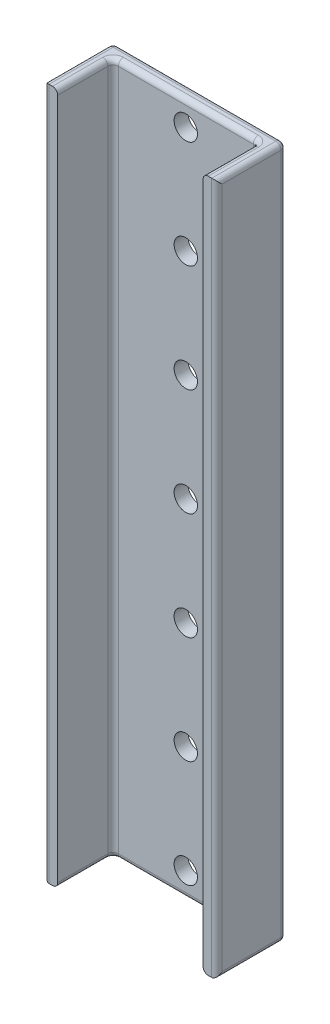
from build123d import *

# Parameters (mm, degrees)
EXTRUIR_L_MINA1_DEPTH         = 400
REDONDEO1_R                   = 3
REDONDEO2_R                   = 3
TALADRO_DE_MARGEN_PARA_M121_D = 13.5


with BuildPart() as part:
    # Croquis1 → Extruir-Lámina1 (new body)
    with BuildSketch(Plane(origin=(0, 0, 0), x_dir=(1, 0, 0), z_dir=(0, 1, 0))):
        with BuildLine():
            Line((50, 0), (50, 37))
            ThreePointArc((50, 37), (49.121320344, 39.121320344), (47, 40))
            Line((47, 40), (-47, 40))
            ThreePointArc((-47, 40), (-49.121320344, 39.121320344), (-50, 37))
            Line((-50, 37), (-50, 0))
            Line((-50, 0), (-42, 0))
            Line((-42, 0), (-42, 32))
            Line((-42, 32), (42, 32))
            Line((42, 32), (42, 0))
            Line((42, 0), (50, 0))
        make_face()
    extrude(amount=EXTRUIR_L_MINA1_DEPTH)

    # Redondeo1
    redondeo1_edges = [part.edges().sort_by_distance(p)[0] for p in [
        (42, 200, -32),
        (-42, 200, -32),
    ]]
    fillet(redondeo1_edges, radius=REDONDEO1_R)

    # Redondeo2
    redondeo2_edges = [part.edges().sort_by_distance(p)[0] for p in [
        (-50, 0, -18.5),
        (-49.121320344, 0, -39.121320344),
        (0, 0, -40),
        (49.121320344, 0, -39.121320344),
        (50, 0, -18.5),
        (50, 400, -18.5),
        (-50, 200, 0),
        (50, 200, 0),
        (49.121320344, 400, -39.121320344),
        (0, 400, -40),
        (-49.121320344, 400, -39.121320344),
        (42, 0, -14.5),
        (-50, 400, -18.5),
        (42, 400, -14.5),
        (0, 0, -32),
        (0, 400, -32),
        (41.121320344, 0, -31.121320344),
        (41.121320344, 400, -31.121320344),
        (-41.121320344, 0, -31.121320344),
        (-41.121320344, 400, -31.121320344),
        (-42, 400, -14.5),
        (-42, 0, -14.5),
    ]]
    fillet(redondeo2_edges, radius=REDONDEO2_R)

    # Taladro de margen para M121 (through all)
    with Locations(Plane(origin=(0, 0, -40), x_dir=(-1, 0, 0), z_dir=(0, 0, -1))):
        with Locations((0, 386), (0, 324), (0, 262), (0, 200), (0, 138), (0, 76), (0, 14)):
            Hole(TALADRO_DE_MARGEN_PARA_M121_D / 2)


solid = part.part
